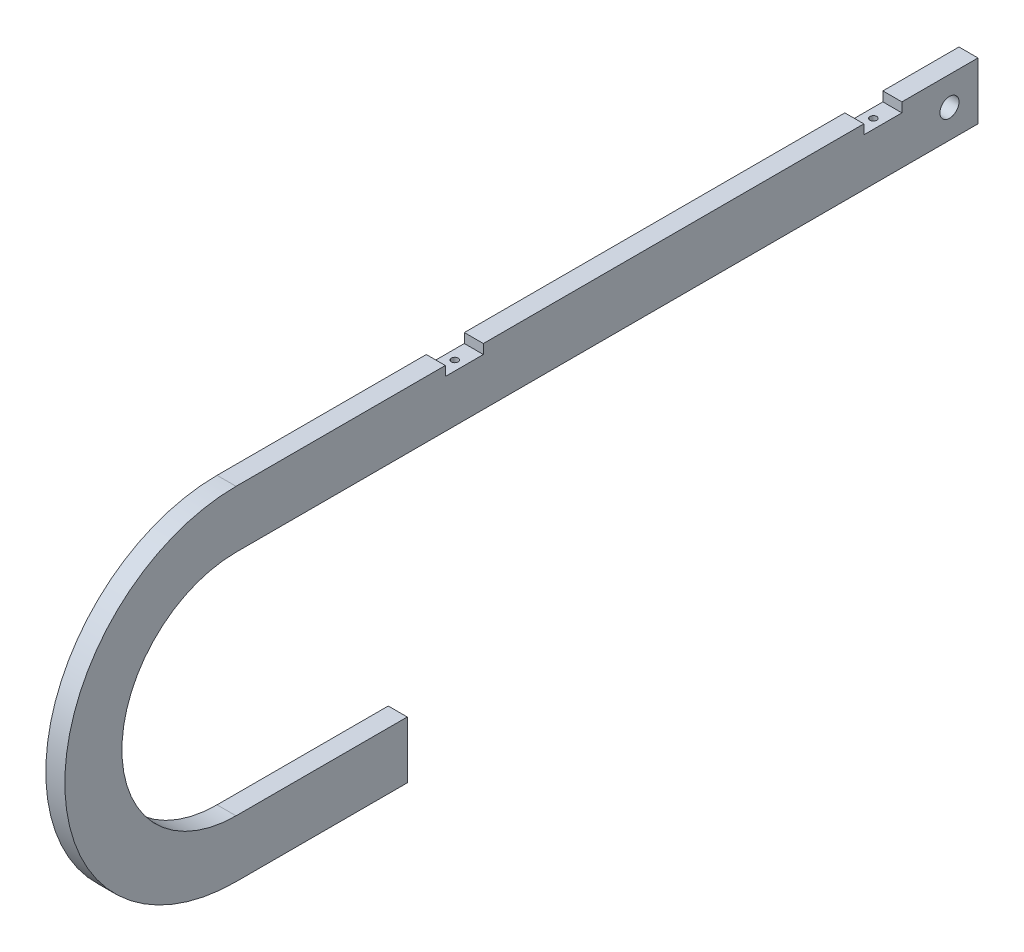
from build123d import *

# Parameters (mm, degrees)
SKETCH1_R                 = 3.175
BOSS_EXTRUDE1_DEPTH       = 3.175
F_4_40_TAPPED_HOLE1_D     = 2.2606
F_4_40_TAPPED_HOLE1_DEPTH = 7.62
F_4_40_TAPPED_HOLE1_TIP   = 0.679152758


with BuildPart() as part:
    # Sketch1 → Boss-Extrude1 (new body, symmetric)
    with BuildSketch(Plane(origin=(0, 0, 0), x_dir=(0, 0, -1), z_dir=(1, 0, 0))):
        with BuildLine():
            Line((57.15, -38.1), (0, -38.1))
            ThreePointArc((0, -38.1), (-38.1, 0), (0, 38.1))
            Line((0, 38.1), (247.65, 38.1))
            Line((247.65, 38.1), (247.65, 57.15))
            Line((247.65, 57.15), (222.25, 57.15))
            Line((222.25, 57.15), (222.25, 53.975))
            Line((222.25, 53.975), (209.55, 53.975))
            Line((209.55, 53.975), (209.55, 57.15))
            Line((209.55, 57.15), (82.55, 57.15))
            Line((82.55, 57.15), (82.55, 53.975))
            Line((82.55, 53.975), (69.85, 53.975))
            Line((69.85, 53.975), (69.85, 57.15))
            Line((69.85, 57.15), (0, 57.15))
            ThreePointArc((0, 57.15), (-57.15, 0), (0, -57.15))
            Line((0, -57.15), (57.15, -57.15))
            Line((57.15, -57.15), (57.15, -38.1))
        make_face()
        with Locations((238.125, 47.625)):
            Circle(SKETCH1_R, mode=Mode.SUBTRACT)
    extrude(amount=BOSS_EXTRUDE1_DEPTH, both=True)

    # #4-40 Tapped Hole1
    with Locations(Plane(origin=(0, 53.975, 0), x_dir=(1, 0, 0), z_dir=(0, 1, 0))):
        with Locations((0, 76.2), (0, 215.9)):
            Hole(F_4_40_TAPPED_HOLE1_D / 2, depth=F_4_40_TAPPED_HOLE1_DEPTH)
            with Locations((0, 0, -(F_4_40_TAPPED_HOLE1_DEPTH + F_4_40_TAPPED_HOLE1_TIP / 2))):  # 118° drill point
                Cone(0, F_4_40_TAPPED_HOLE1_D / 2, F_4_40_TAPPED_HOLE1_TIP, mode=Mode.SUBTRACT)


solid = part.part
